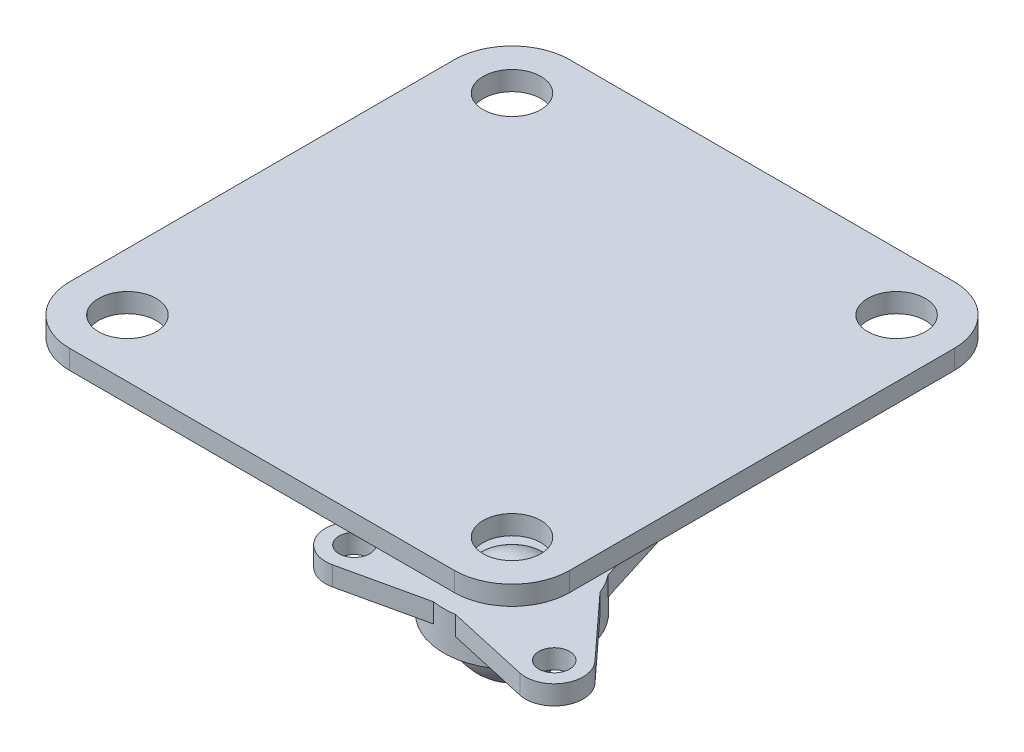
from build123d import *

# Parameters (mm, degrees)
SKETCH1_R           = 1.5
BOSS_EXTRUDE1_DEPTH = 1
SKETCH5_R           = 0.8
BOSS_EXTRUDE2_DEPTH = 1
CIRPATTERN3_COUNT   = 3


with BuildPart() as part:
    # Sketch1 → Boss-Extrude1 (new body)
    with BuildSketch(Plane(origin=(0, 0, 0), x_dir=(1, 0, 0), z_dir=(0, 1, 0))):
        with BuildLine():
            Line((-10, -13), (10, -13))
            ThreePointArc((10, -13), (12.121320344, -12.121320344), (13, -10))
            Line((13, -10), (13, 10))
            ThreePointArc((13, 10), (12.121320344, 12.121320344), (10, 13))
            Line((10, 13), (-10, 13))
            ThreePointArc((-10, 13), (-12.121320344, 12.121320344), (-13, 10))
            Line((-13, 10), (-13, -10))
            ThreePointArc((-13, -10), (-12.121320344, -12.121320344), (-10, -13))
        make_face()
        with Locations((-10, 10)):
            Circle(SKETCH1_R, mode=Mode.SUBTRACT)
        with Locations((10, 10)):
            Circle(SKETCH1_R, mode=Mode.SUBTRACT)
        with Locations((-10, -10)):
            Circle(SKETCH1_R, mode=Mode.SUBTRACT)
        with Locations((10, -10)):
            Circle(SKETCH1_R, mode=Mode.SUBTRACT)
    extrude(amount=-BOSS_EXTRUDE1_DEPTH)


with BuildPart() as body_2:
    # Sketch2 → Revolve2 (revolve)
    with BuildSketch(Plane.XY):
        with BuildLine():
            Line((0, -10.9), (0, -16))
            ThreePointArc((0, -16), (2.55, -13.45), (0, -10.9))
        make_face()
    revolve(axis=Axis((0, -13.45, 0), (0, 1, 0)))

    # Sketch4 → Revolve3 (revolve)
    with BuildSketch(Plane.XY):
        with BuildLine():
            Line((2.55, -13.45), (3.55, -13.45))
            Line((3.55, -13.45), (3.55, -11.45))
            Line((3.55, -11.45), (1.581929202, -11.45))
            ThreePointArc((1.581929202, -11.45), (2.295258097, -12.339013831), (2.55, -13.45))
        make_face()
    revolve(axis=Axis((0, -13.45, 0), (0, 1, 0)))

    # Sketch5 → Boss-Extrude2 (add)
    with BuildSketch(Plane(origin=(0, -11.45, 0), x_dir=(1, 0, 0), z_dir=(0, 1, 0))):
        with BuildLine():
            Line((-2.75, 2.244994432), (-1.431232042, 6.44897087))
            ThreePointArc((-1.431232042, 6.44897087), (0, 7.5), (1.431232042, 6.44897087))
            Line((1.431232042, 6.44897087), (2.75, 2.244994432))
            ThreePointArc((2.75, 2.244994432), (0, 3.55), (-2.75, 2.244994432))
        make_face()
        with Locations((0, 6)):
            Circle(SKETCH5_R, mode=Mode.SUBTRACT)
    boss_extrude2 = extrude(amount=-BOSS_EXTRUDE2_DEPTH)

    # CirPattern3: Boss-Extrude2 ×3 about axis
    cirpattern3_axis = Axis((0, 0, 0), (0, 1, 0))
    for i in range(1, CIRPATTERN3_COUNT):
        add(boss_extrude2.rotate(cirpattern3_axis, i * 360 / CIRPATTERN3_COUNT))


solid = Compound([part.part, body_2.part])
